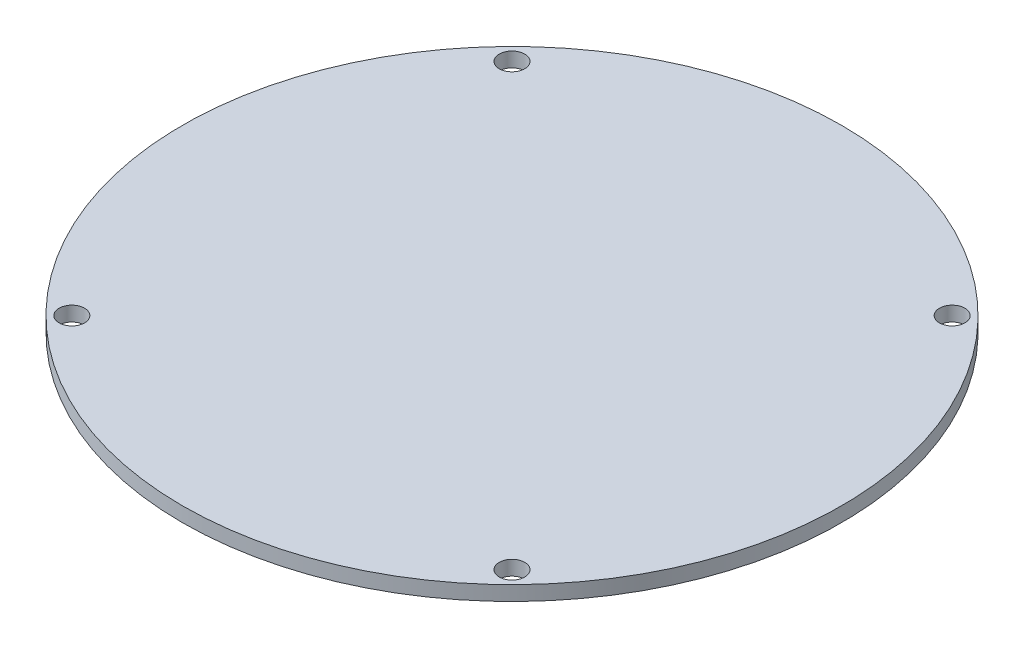
from build123d import *

# Parameters (mm, degrees)
SKETCH1_R           = 57.15
BOSS_EXTRUDE1_DEPTH = 2.54
SKETCH2_R           = 2.21082771
CUT_EXTRUDE1_DEPTH  = 3.54


with BuildPart() as part:
    # Sketch1 → Boss-Extrude1 (new body)
    with BuildSketch(Plane(origin=(0, 0, 0), x_dir=(1, 0, 0), z_dir=(0, 1, 0))):
        Circle(SKETCH1_R)
    extrude(amount=BOSS_EXTRUDE1_DEPTH)

    # Sketch2 → Cut-Extrude1 (cut, through all)
    with BuildSketch(Plane(origin=(0, 2.54, 0), x_dir=(1, 0, 0), z_dir=(0, 1, 0))):
        with Locations((-38.166088515, 38.166088515)):
            Circle(SKETCH2_R)
        with Locations((38.166088515, 38.166088515)):
            Circle(SKETCH2_R)
        with Locations((38.166088515, -38.166088515)):
            Circle(SKETCH2_R)
        with Locations((-38.166088515, -38.166088515)):
            Circle(SKETCH2_R)
    extrude(amount=-CUT_EXTRUDE1_DEPTH, mode=Mode.SUBTRACT)


solid = part.part
